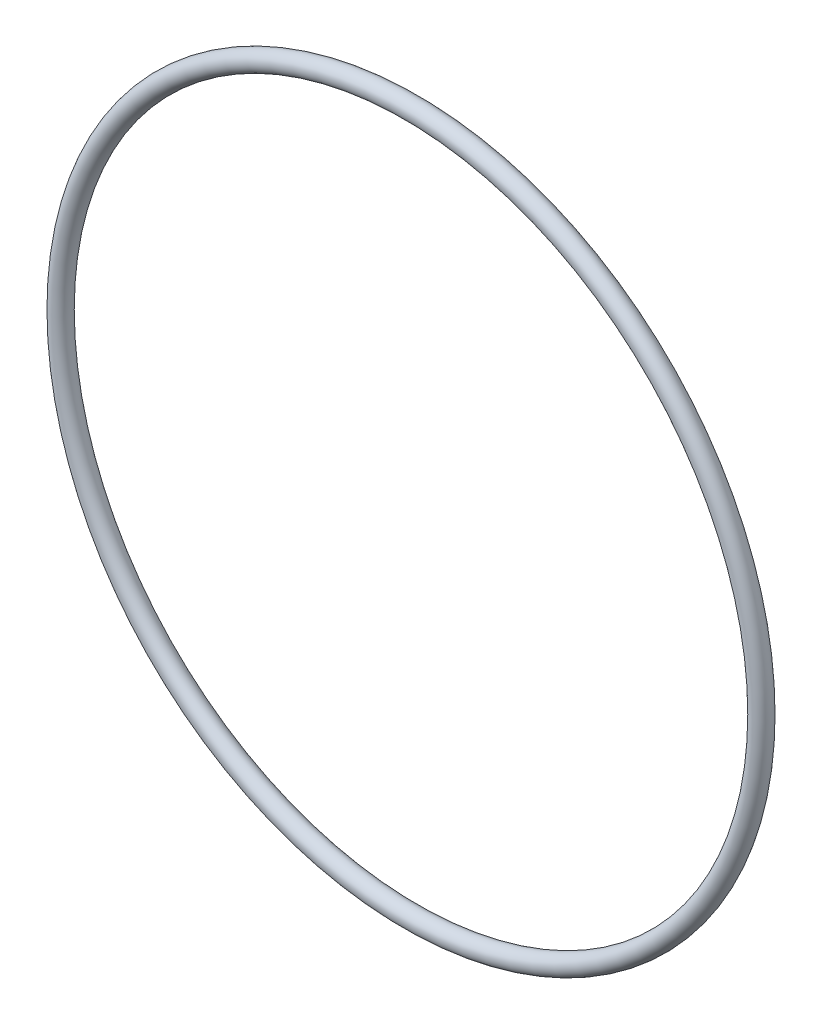
from build123d import *

# Parameters (mm, degrees)
SKETCH2_R = 1.55


with BuildPart() as part:
    # Sweep1: sweep along a path in Sketch1
    with BuildLine(Plane.XY) as sweep1_path:
        CenterArc((0, 0), 54.7, 0, 360)
    # Sketch2 → Sweep1 (sweep)
    with BuildSketch(Plane(origin=(0, 0, 0), x_dir=(1, 0, 0), z_dir=(0, 1, 0))):
        with Locations((-56.25, 0)):
            Circle(SKETCH2_R)
    sweep(path=sweep1_path.line)


solid = part.part
